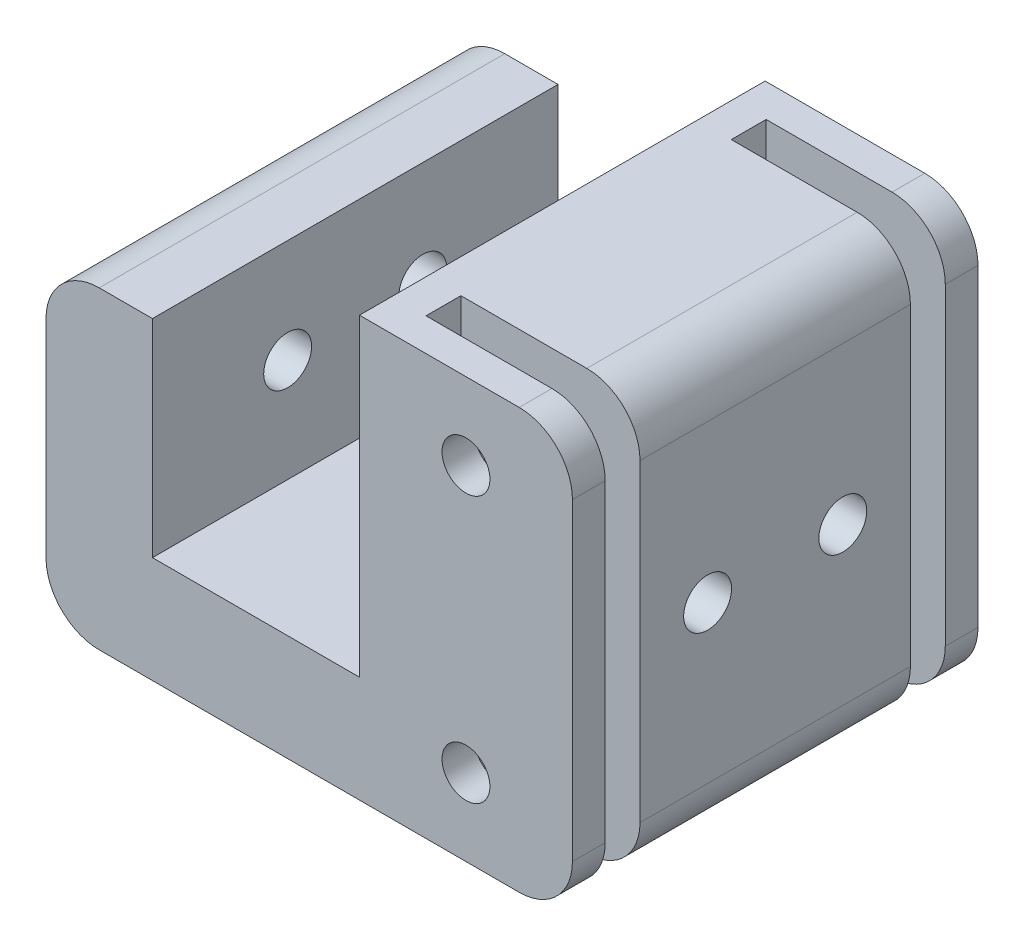
from build123d import *

# Parameters (mm, degrees)
SKETCH1_R               = 2.25
BOSS_EXTRUDE1_DEPTH     = 19.05
SKETCH2_W               = 16.825
SKETCH2_H               = 3.275
CUT_EXTRUDE1_DEPTH      = 20.725
CUT_EXTRUDE1_DEPTH_BACK = 20.725
SKETCH4_R               = 2.25
CUT_EXTRUDE2_DEPTH      = 30.725
CUT_EXTRUDE2_DEPTH_BACK = 20.725


with BuildPart() as part:
    # Sketch1 → Boss-Extrude1 (new body, symmetric)
    with BuildSketch(Plane.XY):
        with BuildLine():
            Line((-9.725, 9.725), (-14.725, 9.725))
            ThreePointArc((-14.725, 9.725), (-18.260533906, 8.260533906), (-19.725, 4.725))
            Line((-19.725, 4.725), (-19.725, -14.725))
            ThreePointArc((-19.725, -14.725), (-18.260533906, -18.260533906), (-14.725, -19.725))
            Line((-14.725, -19.725), (24.725, -19.725))
            ThreePointArc((24.725, -19.725), (28.260533906, -18.260533906), (29.725, -14.725))
            Line((29.725, -14.725), (29.725, 14.725))
            ThreePointArc((29.725, 14.725), (28.260533906, 18.260533906), (24.725, 19.725))
            Line((24.725, 19.725), (9.725, 19.725))
            Line((9.725, 19.725), (9.725, 9.725))
            Line((9.725, 9.725), (9.725, -9.725))
            Line((9.725, -9.725), (-9.725, -9.725))
            Line((-9.725, -9.725), (-9.725, 9.725))
        make_face()
        with Locations((19.725, 12.5)):
            Circle(SKETCH1_R, mode=Mode.SUBTRACT)
        with Locations((19.725, -12.5)):
            Circle(SKETCH1_R, mode=Mode.SUBTRACT)
    extrude(amount=BOSS_EXTRUDE1_DEPTH, both=True)

    # Sketch2 → Cut-Extrude1 (cut, two sides)
    with BuildSketch(Plane(origin=(0, 0, 0), x_dir=(1, 0, 0), z_dir=(0, 1, 0))) as cut_extrude1_sk:
        with Locations((21.3125, 14.3375)):
            Rectangle(SKETCH2_W, SKETCH2_H)
        with Locations((21.3125, -14.3375)):
            Rectangle(SKETCH2_W, SKETCH2_H)
    extrude(amount=CUT_EXTRUDE1_DEPTH, mode=Mode.SUBTRACT)
    extrude(cut_extrude1_sk.sketch, amount=-CUT_EXTRUDE1_DEPTH_BACK, mode=Mode.SUBTRACT)

    # Sketch4 → Cut-Extrude2 (cut, two sides)
    with BuildSketch(Plane(origin=(0, 0, 0), x_dir=(0, 0, -1), z_dir=(1, 0, 0))) as cut_extrude2_sk:
        with Locations((-6.35, 0)):
            Circle(SKETCH4_R)
        with Locations((6.35, 0)):
            Circle(SKETCH4_R)
    extrude(amount=CUT_EXTRUDE2_DEPTH, mode=Mode.SUBTRACT)
    extrude(cut_extrude2_sk.sketch, amount=-CUT_EXTRUDE2_DEPTH_BACK, mode=Mode.SUBTRACT)


solid = part.part
